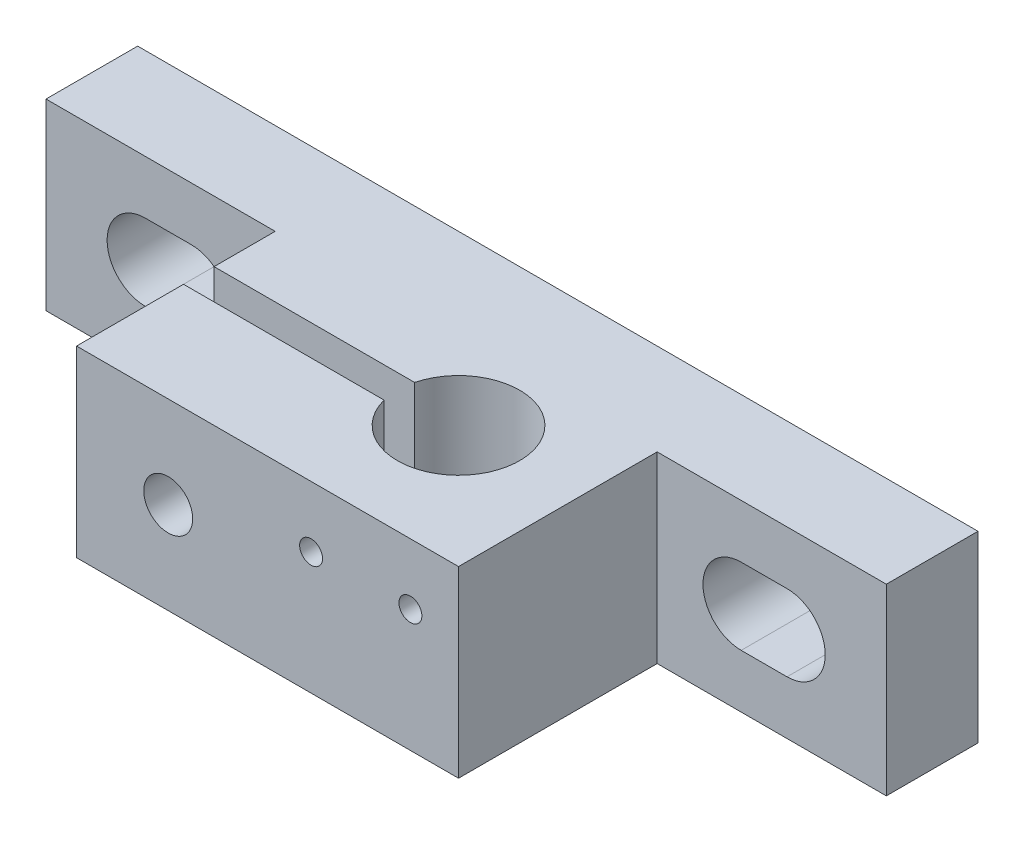
from build123d import *

# Parameters (mm, degrees)
SKETCH2_W           = 55
SKETCH2_H           = 12
BOSS_EXTRUDE1_DEPTH = 6
SKETCH3_W           = 25
SKETCH3_H           = 12
BOSS_EXTRUDE2_DEPTH = 13
SKETCH4_R           = 4
CUT_EXTRUDE2_DEPTH  = 30
SKETCH5_W           = 20.513890507
SKETCH5_H           = 7
CUT_EXTRUDE3_DEPTH  = 5
SKETCH6_R           = 1.6
CUT_EXTRUDE4_DEPTH  = 11
CUT_EXTRUDE5_DEPTH  = 3
SKETCH8_R           = 0.75
CUT_EXTRUDE6_DEPTH  = 3


with BuildPart() as part:
    # Sketch2 → Boss-Extrude1 (new body)
    with BuildSketch(Plane.XY):
        with Locations((27.5, 6)):
            Rectangle(SKETCH2_W, SKETCH2_H)
        with BuildLine():
            Line((6.5, 8.5), (9.5, 8.5))
            ThreePointArc((9.5, 8.5), (12, 6), (9.5, 3.5))
            Line((9.5, 3.5), (6.5, 3.5))
            ThreePointArc((6.5, 3.5), (4, 6), (6.5, 8.5))
        make_face(mode=Mode.SUBTRACT)
        with BuildLine():
            Line((48.5, 8.5), (45.5, 8.5))
            ThreePointArc((45.5, 8.5), (43, 6), (45.5, 3.5))
            Line((45.5, 3.5), (48.5, 3.5))
            ThreePointArc((48.5, 3.5), (51, 6), (48.5, 8.5))
        make_face(mode=Mode.SUBTRACT)
    extrude(amount=BOSS_EXTRUDE1_DEPTH)

    # Sketch3 → Boss-Extrude2 (add)
    with BuildSketch(Plane.XY.offset(6)):
        with Locations((27.5, 6)):
            Rectangle(SKETCH3_W, SKETCH3_H)
    extrude(amount=BOSS_EXTRUDE2_DEPTH)

    # Sketch4 → Cut-Extrude2 (cut)
    with BuildSketch(Plane.XZ):
        with BuildLine():
            ThreePointArc((28.127016654, 10), (28, 11), (28.127016654, 12))
            Line((28.127016654, 12), (15, 12))
            Line((15, 12), (15, 10))
            Line((15, 10), (28.127016654, 10))
        make_face()
        with Locations((32, 11)):
            Circle(SKETCH4_R)
    extrude(amount=-CUT_EXTRUDE2_DEPTH, mode=Mode.SUBTRACT)

    # Sketch5 → Cut-Extrude3 (cut)
    with BuildSketch(Plane(origin=(0, 0, 0), x_dir=(-1, 0, 0), z_dir=(0, 0, -1))):
        with Locations((-27.415473723, 6)):
            Rectangle(SKETCH5_W, SKETCH5_H)
    extrude(amount=-CUT_EXTRUDE3_DEPTH, mode=Mode.SUBTRACT)

    # Sketch6 → Cut-Extrude4 (cut)
    with BuildSketch(Plane.XY.offset(19)):
        with Locations((21, 6)):
            Circle(SKETCH6_R)
    extrude(amount=-CUT_EXTRUDE4_DEPTH, mode=Mode.SUBTRACT)

    # Sketch7 → Cut-Extrude5 (cut)
    with BuildSketch(Plane(origin=(0, 0, 5), x_dir=(-1, 0, 0), z_dir=(0, 0, -1))):
        Polygon((-17.535898385, 6), (-19.267949192, 9), (-22.732050808, 9), (-24.464101615, 6), (-22.732050808, 3), (-19.267949192, 3), align=None)
    extrude(amount=-CUT_EXTRUDE5_DEPTH, mode=Mode.SUBTRACT)

    # Sketch8 → Cut-Extrude6 (cut)
    with BuildSketch(Plane.XY.offset(19)):
        with Locations((36.85, 8)):
            Circle(SKETCH8_R)
        with Locations((30.35, 8)):
            Circle(SKETCH8_R)
    extrude(amount=-CUT_EXTRUDE6_DEPTH, mode=Mode.SUBTRACT)


solid = part.part
